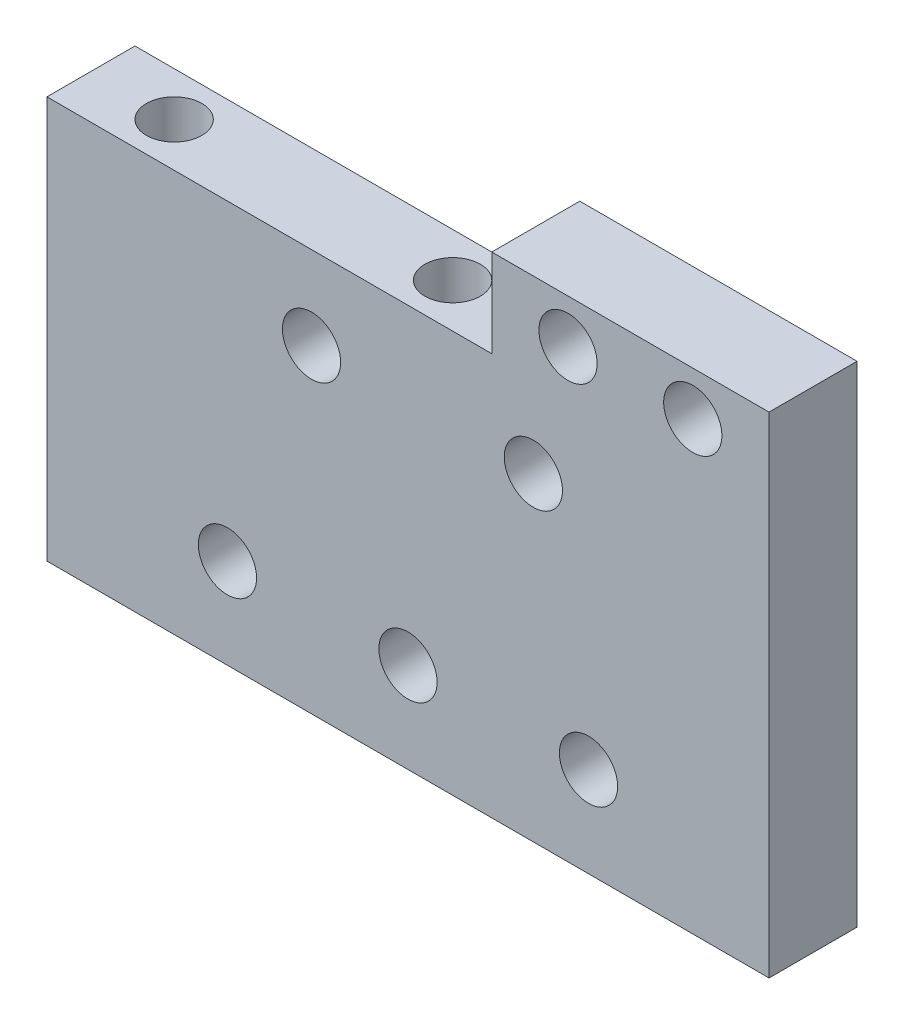
from build123d import *

# Parameters (mm, degrees)
SKETCH1_R           = 2.1
BOSS_EXTRUDE1_DEPTH = 6.35
SKETCH2_R           = 2.1
CUT_EXTRUDE1_DEPTH  = 7.35
SKETCH3_R           = 2
CUT_EXTRUDE2_DEPTH  = 8


with BuildPart() as part:
    # Sketch1 → Boss-Extrude1 (new body)
    with BuildSketch(Plane.XY):
        Polygon((90, 6.35), (110, 6.35), (110, -29), (57.914505889, -29), (57.914505889, 0), (90, 0), align=None)
        with Locations((95.5, 3.175)):
            Circle(SKETCH1_R, mode=Mode.SUBTRACT)
        with Locations((104.5, 3.175)):
            Circle(SKETCH1_R, mode=Mode.SUBTRACT)
    extrude(amount=BOSS_EXTRUDE1_DEPTH)

    # Sketch2 → Cut-Extrude1 (cut, through all)
    with BuildSketch(Plane.XY.offset(6.35)):
        with Locations((70.935879417, -22.5)):
            Circle(SKETCH2_R)
        with Locations((83.957252945, -22.5)):
            Circle(SKETCH2_R)
        with Locations((96.978626472, -22.5)):
            Circle(SKETCH2_R)
        with Locations((93, -6)):
            Circle(SKETCH2_R)
        with Locations((77, -6)):
            Circle(SKETCH2_R)
    extrude(amount=-CUT_EXTRUDE1_DEPTH, mode=Mode.SUBTRACT)

    # Sketch3 → Cut-Extrude2 (cut)
    with BuildSketch(Plane(origin=(0, 0, 0), x_dir=(-1, 0, 0), z_dir=(0, 1, 0))):
        with Locations((-84, 3.175)):
            Circle(SKETCH3_R)
        with Locations((-63.914505889, 3.175)):
            Circle(SKETCH3_R)
    extrude(amount=-CUT_EXTRUDE2_DEPTH, mode=Mode.SUBTRACT)


solid = part.part
